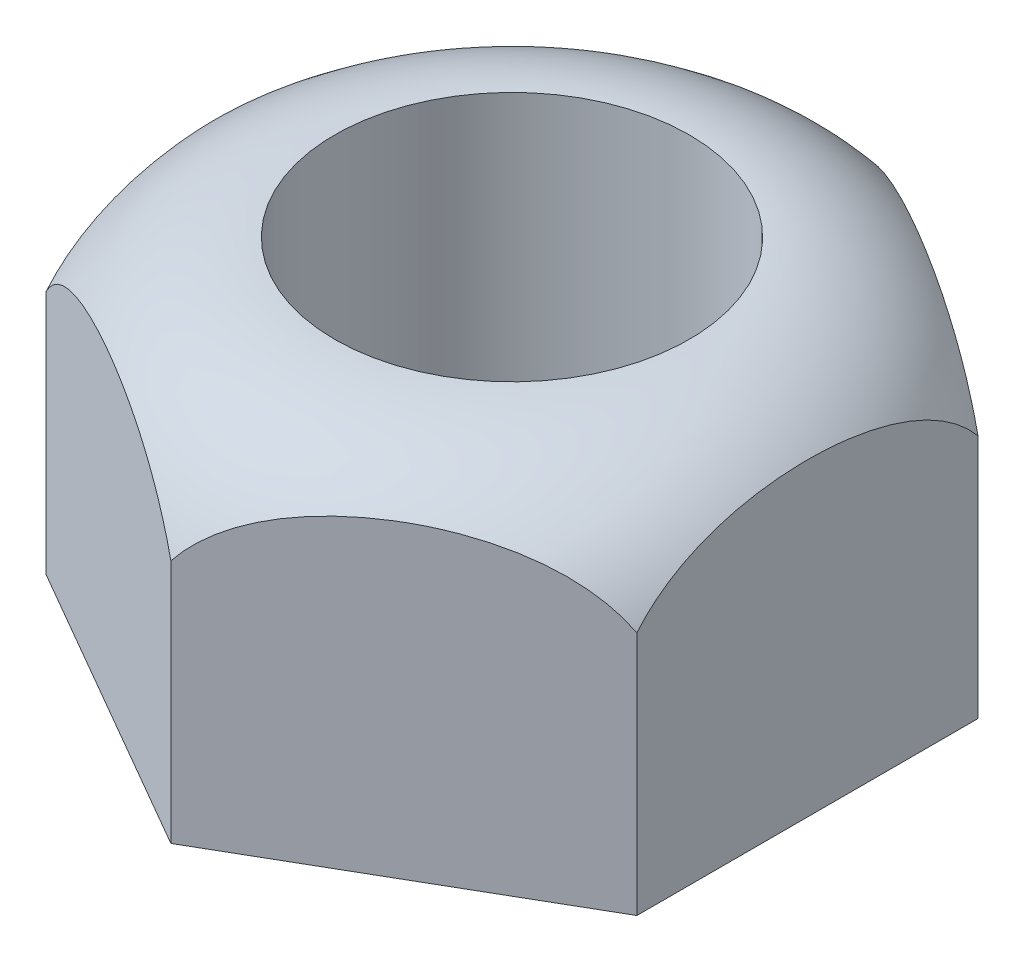
from build123d import *

# Parameters (mm, degrees)
SKETCH3_R           = 3
BOSS_EXTRUDE1_DEPTH = 3


with BuildPart() as part:
    # Sketch3 → Boss-Extrude1 (new, symmetric)
    with BuildSketch(Plane(origin=(0, 0, 0), x_dir=(1, 0, 0), z_dir=(0, 1, 0))):
        Polygon((5, 2.886751346), (0, 5.773502692), (-5, 2.886751346), (-5, -2.886751346), (0, -5.773502692), (5, -2.886751346), align=None)
        Circle(SKETCH3_R, mode=Mode.SUBTRACT)
    extrude(amount=BOSS_EXTRUDE1_DEPTH, both=True)

    # Sketch5 → Cut-Revolve1 (revolve, cut)
    with BuildSketch(Plane(origin=(0, 0, 0), x_dir=(0, 0, -1), z_dir=(1, 0, 0))):
        with BuildLine():
            Line((3, 3), (5.773502692, 3))
            Line((5.773502692, 3), (5.773502692, 1.143539601))
            ThreePointArc((5.773502692, 1.143539601), (4.668739224, 2.493052226), (3, 3))
        make_face()
    revolve(axis=Axis((0, 0, 0), (0, 1, 0)), mode=Mode.SUBTRACT)


solid = part.part
